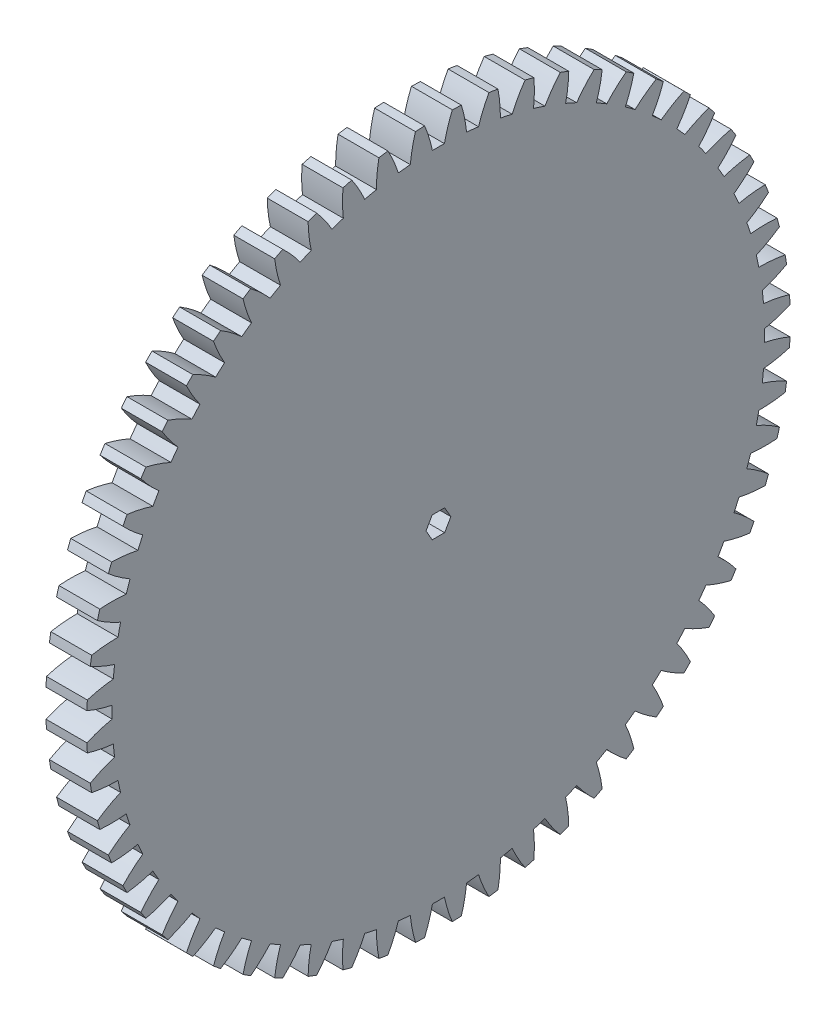
from build123d import *

# Parameters (mm, degrees)
BASPROSKE_W         = 3.81
BASPROSKE_H         = 32.808333333
TOOTHCUT_DEPTH      = 47.554157411
TEETHCUTS_COUNT     = 60
TEETHCUTS_ANGLE     = 354
BORSKE_R            = 6.35
BORE_DEPTH          = 50.8000508
SKETCH1_R           = 6.35
BOSS_EXTRUDE1_DEPTH = 7.62
CUT_EXTRUDE1_DEPTH  = 47.983982628


with BuildPart() as part:
    # BasProSke → Base-Revolve (revolve)
    with BuildSketch(Plane(origin=(0, 0, 0), x_dir=(1, 0, 0), z_dir=(0, 1, 0)), mode=Mode.PRIVATE) as base_revolve_sk:
        with Locations((1.905, 16.404166667)):
            Rectangle(BASPROSKE_W, BASPROSKE_H)
    revolve(base_revolve_sk.sketch.rotate(Axis((-10, 0, 0), (1, 0, 0)), 180), axis=Axis((-10, 0, 0), (1, 0, 0)))

    # TooCutSke → ToothCut (cut, through all)
    with BuildSketch(Plane(origin=(0, 0, 0), x_dir=(0, 0, -1), z_dir=(1, 0, 0))):
        with BuildLine():
            ThreePointArc((0.560504786, 30.424037323), (0, 30.4292), (-0.560504786, 30.424037323))
            ThreePointArc((-0.560504786, 30.424037323), (-0.873260741, 31.63424693), (-1.303469743, 32.807849842))
            ThreePointArc((-1.303469743, 32.807849842), (0, 32.833733333), (1.303469743, 32.807849842))
            ThreePointArc((1.303469743, 32.807849842), (0.873260741, 31.63424693), (0.560504786, 30.424037323))
        make_face()
    toothcut = extrude(amount=TOOTHCUT_DEPTH, mode=Mode.SUBTRACT)

    # TeethCuts: ToothCut ×60 about axis
    teethcuts_axis = Axis((-10, 0, 0), (1, 0, 0))
    for i in range(1, TEETHCUTS_COUNT):
        add(toothcut.rotate(teethcuts_axis, i * TEETHCUTS_ANGLE / (TEETHCUTS_COUNT - 1)), mode=Mode.SUBTRACT)

    # BorSke → Bore (cut, symmetric)
    with BuildSketch(Plane(origin=(0, 0, 0), x_dir=(0, 0, -1), z_dir=(1, 0, 0))):
        with Locations(Location((0, 0, 0), (0, 0, 180))):
            Circle(BORSKE_R)
    extrude(amount=BORE_DEPTH, both=True, mode=Mode.SUBTRACT)

    # Sketch1 → Boss-Extrude1 (add)
    with BuildSketch(Plane(origin=(3.81, 0, 0), x_dir=(0, 0, -1), z_dir=(1, 0, 0))):
        Circle(SKETCH1_R)
    extrude(amount=-BOSS_EXTRUDE1_DEPTH)

    # Sketch2 → Cut-Extrude1 (cut, through all)
    with BuildSketch(Plane.ZY.offset(3.81)):
        Polygon((1.15851105, 0), (0.579255525, 1.0033), (-0.579255525, 1.0033), (-1.15851105, 0), (-0.579255525, -1.0033), (0.579255525, -1.0033), align=None)
    extrude(amount=-CUT_EXTRUDE1_DEPTH, mode=Mode.SUBTRACT)


solid = part.part
